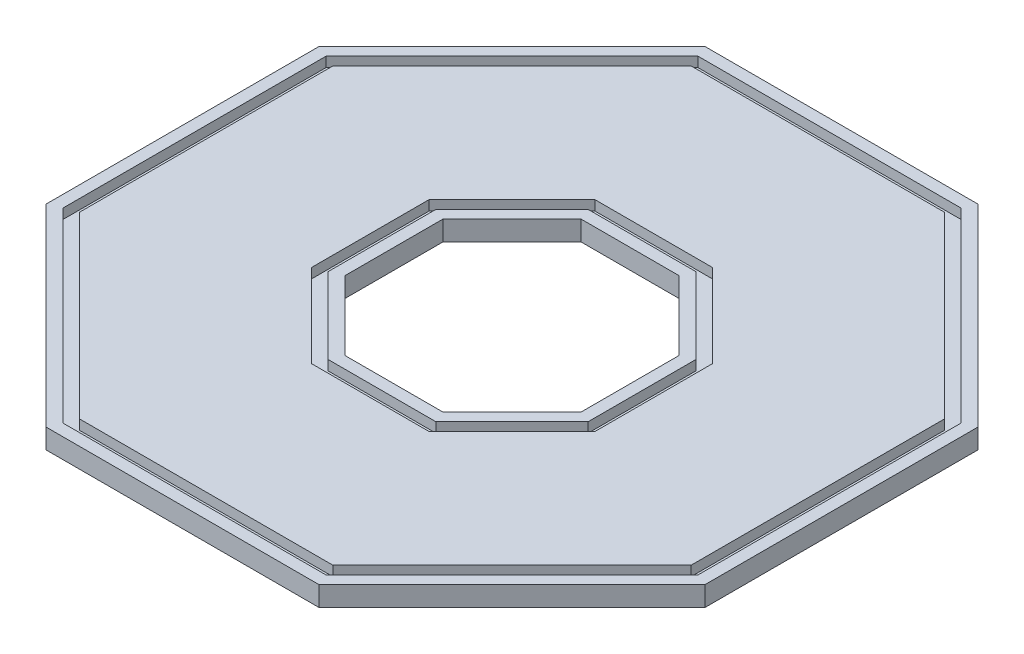
from build123d import *

# Parameters (mm, degrees)
EXTRUDE_1_DEPTH     = 2
CUT_EXTRUDE_1_DEPTH = 1
CUT_EXTRUDE_2_DEPTH = 1
CUT_EXTRUDE_3_DEPTH = 3


with BuildPart() as part:
    # 스케치1 → 보스-돌출1 (new body)
    with BuildSketch(Plane(origin=(0, 0, 0), x_dir=(1, 0, 0), z_dir=(0, 1, 0))):
        Polygon((-33.25966317, -13.776603565), (-13.776603565, -33.25966317), (13.776603565, -33.25966317), (33.25966317, -13.776603565), (33.25966317, 13.776603565), (13.776603565, 33.25966317), (-13.776603565, 33.25966317), (-33.25966317, 13.776603565), align=None)
        Polygon((-13.27954729, -32.05966317), (13.27954729, -32.05966317), (32.05966317, -13.27954729), (32.05966317, 13.27954729), (13.27954729, 32.05966317), (-13.27954729, 32.05966317), (-32.05966317, 13.27954729), (-32.05966317, -13.27954729), align=None, mode=Mode.SUBTRACT)
        Polygon((-32.05966317, -13.27954729), (-13.27954729, -32.05966317), (13.27954729, -32.05966317), (32.05966317, -13.27954729), (32.05966317, 13.27954729), (13.27954729, 32.05966317), (-13.27954729, 32.05966317), (-32.05966317, 13.27954729), align=None)
    extrude(amount=EXTRUDE_1_DEPTH)

    # 스케치2 → 컷-돌출1 (cut)
    with BuildSketch(Plane(origin=(0, 2, 0), x_dir=(1, 0, 0), z_dir=(0, 1, 0))):
        Polygon((-32.05966317, -13.27954729), (-13.27954729, -32.05966317), (13.27954729, -32.05966317), (32.05966317, -13.27954729), (32.05966317, 13.27954729), (13.27954729, 32.05966317), (-13.27954729, 32.05966317), (-32.05966317, 13.27954729), align=None)
        Polygon((-30.85966317, -12.782491015), (-12.782491015, -30.85966317), (12.782491015, -30.85966317), (30.85966317, -12.782491015), (30.85966317, 12.782491015), (12.782491015, 30.85966317), (-12.782491015, 30.85966317), (-30.85966317, 12.782491015), align=None, mode=Mode.SUBTRACT)
    extrude(amount=-CUT_EXTRUDE_1_DEPTH, mode=Mode.SUBTRACT)

    # 스케치3 → 컷-돌출2 (cut)
    with BuildSketch(Plane(origin=(0, 2, 0), x_dir=(1, 0, 0), z_dir=(0, 1, 0))):
        Polygon((-14.320132754, -5.931593202), (-5.931593202, -14.320132754), (5.931593202, -14.320132754), (14.320132754, -5.931593202), (14.320132754, 5.931593202), (5.931593202, 14.320132754), (-5.931593202, 14.320132754), (-14.320132754, 5.931593202), align=None)
        Polygon((-5.434536927, -13.120132754), (5.434536927, -13.120132754), (13.120132754, -5.434536927), (13.120132754, 5.434536927), (5.434536927, 13.120132754), (-5.434536927, 13.120132754), (-13.120132754, 5.434536927), (-13.120132754, -5.434536927), align=None, mode=Mode.SUBTRACT)
    extrude(amount=-CUT_EXTRUDE_2_DEPTH, mode=Mode.SUBTRACT)

    # 스케치3<3> → 컷-돌출3 (cut)
    with BuildSketch(Plane(origin=(0, 2, 0), x_dir=(1, 0, 0), z_dir=(0, 1, 0))):
        Polygon((4.937480652, -11.920132754), (11.920132754, -4.937480652), (11.920132754, 4.937480652), (4.937480652, 11.920132754), (-4.937480652, 11.920132754), (-11.920132754, 4.937480652), (-11.920132754, -4.937480652), (-4.937480652, -11.920132754), align=None)
    extrude(amount=-CUT_EXTRUDE_3_DEPTH, mode=Mode.SUBTRACT)


solid = part.part
